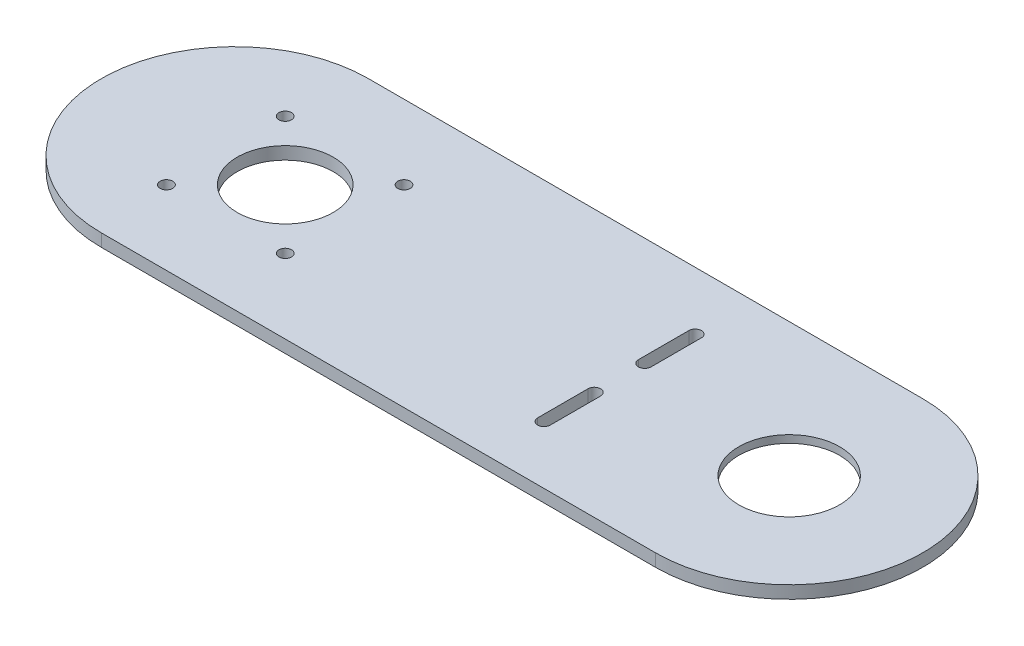
from build123d import *

# Parameters (mm, degrees)
BOSS_EXTRUDE1_DEPTH = 5
SKETCH2_R           = 20
CUT_EXTRUDE1_DEPTH  = 6
SKETCH3_R           = 30
CUT_EXTRUDE2_DEPTH  = 2
SKETCH4_R           = 2.5
SKETCH4_R_2         = 19.05
CUT_EXTRUDE3_DEPTH  = 6


with BuildPart() as part:
    # Sketch1 → Boss-Extrude1 (new body)
    with BuildSketch(Plane(origin=(0, 0, 0), x_dir=(1, 0, 0), z_dir=(0, 1, 0))):
        with BuildLine():
            ThreePointArc((-110, 53), (-163, 0), (-110, -53))
            Line((-110, -53), (-110, 53))
        make_face()
        with BuildLine():
            Line((-110, 53), (-110, -53))
            ThreePointArc((-110, -53), (-72.523340597, -37.476659403), (-57, 0))
            ThreePointArc((-57, 0), (-72.523340597, 37.476659403), (-110, 53))
        make_face()
        with BuildLine():
            ThreePointArc((-57, 0), (-72.523340597, -37.476659403), (-110, -53))
            Line((-110, -53), (110, -53))
            ThreePointArc((110, -53), (57, 0), (110, 53))
            Line((110, 53), (-110, 53))
            ThreePointArc((-110, 53), (-72.523340597, 37.476659403), (-57, 0))
        make_face()
        with BuildLine():
            ThreePointArc((110, 53), (57, 0), (110, -53))
            Line((110, -53), (110, 53))
        make_face()
        with BuildLine():
            Line((110, 53), (110, -53))
            ThreePointArc((110, -53), (147.476659403, -37.476659403), (163, 0))
            ThreePointArc((163, 0), (147.476659403, 37.476659403), (110, 53))
        make_face()
    extrude(amount=BOSS_EXTRUDE1_DEPTH)

    # Sketch2 → Cut-Extrude1 (cut, through all)
    with BuildSketch(Plane(origin=(0, 5, 0), x_dir=(1, 0, 0), z_dir=(0, 1, 0))):
        with Locations((110, 0)):
            Circle(SKETCH2_R)
    extrude(amount=-CUT_EXTRUDE1_DEPTH, mode=Mode.SUBTRACT)

    # Sketch3 → Cut-Extrude2 (cut)
    with BuildSketch(Plane.XZ):
        with Locations((110, 0)):
            Circle(SKETCH3_R)
    extrude(amount=-CUT_EXTRUDE2_DEPTH, mode=Mode.SUBTRACT)

    # Sketch4 → Cut-Extrude3 (cut, through all)
    with BuildSketch(Plane(origin=(0, 5, 0), x_dir=(1, 0, 0), z_dir=(0, 1, 0))):
        with Locations((-113.57, 23.57)):
            Circle(SKETCH4_R)
        with Locations((-66.43, 23.57)):
            Circle(SKETCH4_R)
        with Locations((-66.43, -23.57)):
            Circle(SKETCH4_R)
        with Locations((-113.57, -23.57)):
            Circle(SKETCH4_R)
        with Locations((-90, 0)):
            Circle(SKETCH4_R_2)
        with BuildLine():
            Line((45.182638641, 10), (45.182638641, 30))
            ThreePointArc((45.182638641, 30), (42.682638641, 32.5), (40.182638641, 30))
            Line((40.182638641, 30), (40.182638641, 10))
            ThreePointArc((40.182638641, 10), (42.682638641, 7.5), (45.182638641, 10))
        make_face()
        with BuildLine():
            Line((40.182638641, -10), (40.182638641, -30))
            ThreePointArc((40.182638641, -30), (42.682638641, -32.5), (45.182638641, -30))
            Line((45.182638641, -30), (45.182638641, -10))
            ThreePointArc((45.182638641, -10), (42.682638641, -7.5), (40.182638641, -10))
        make_face()
    extrude(amount=-CUT_EXTRUDE3_DEPTH, mode=Mode.SUBTRACT)


solid = part.part
